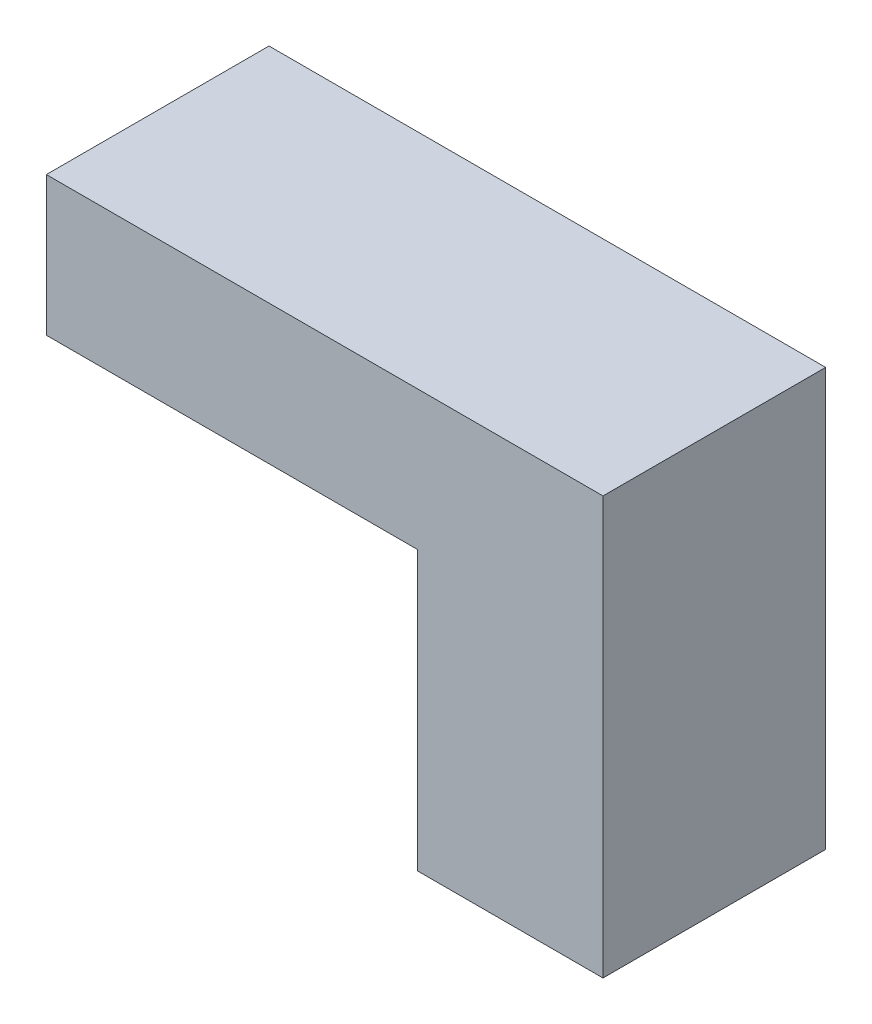
from build123d import *

# Parameters (mm, degrees)
BOSS_EXTRUDE1_DEPTH = 6.096


with BuildPart() as part:
    # Sketch2 → Boss-Extrude1 (new body)
    with BuildSketch(Plane.XY):
        Polygon((0, 0), (15.24, 0), (15.24, -11.43), (10.16, -11.43), (10.16, -3.81), (0, -3.81), align=None)
    extrude(amount=BOSS_EXTRUDE1_DEPTH)


solid = part.part
